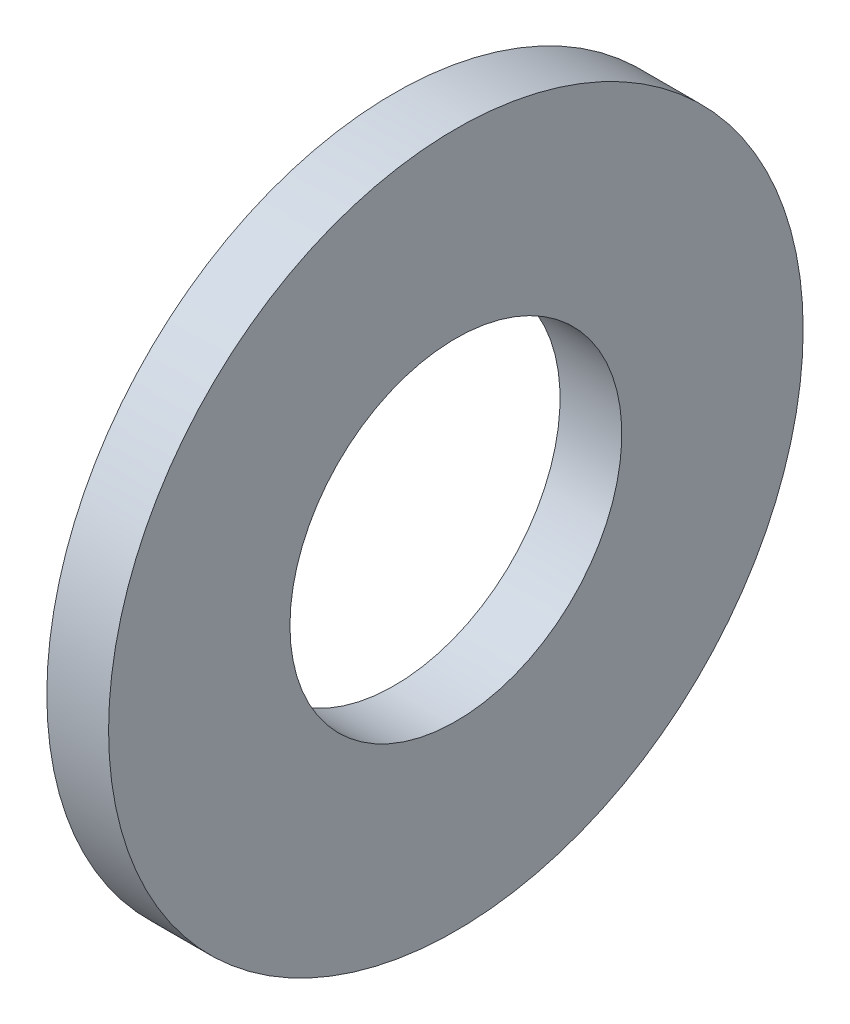
from build123d import *

# Parameters (mm, degrees)
SKETCH1_W = 0.8
SKETCH1_H = 2.35


with BuildPart() as part:
    # Sketch1 → Base-Revolve (revolve)
    with BuildSketch(Plane.XY):
        with Locations((-0.4, 3.325)):
            Rectangle(SKETCH1_W, SKETCH1_H)
    revolve(axis=Axis((-34.925, 0, 0), (1, 0, 0)))


solid = part.part
